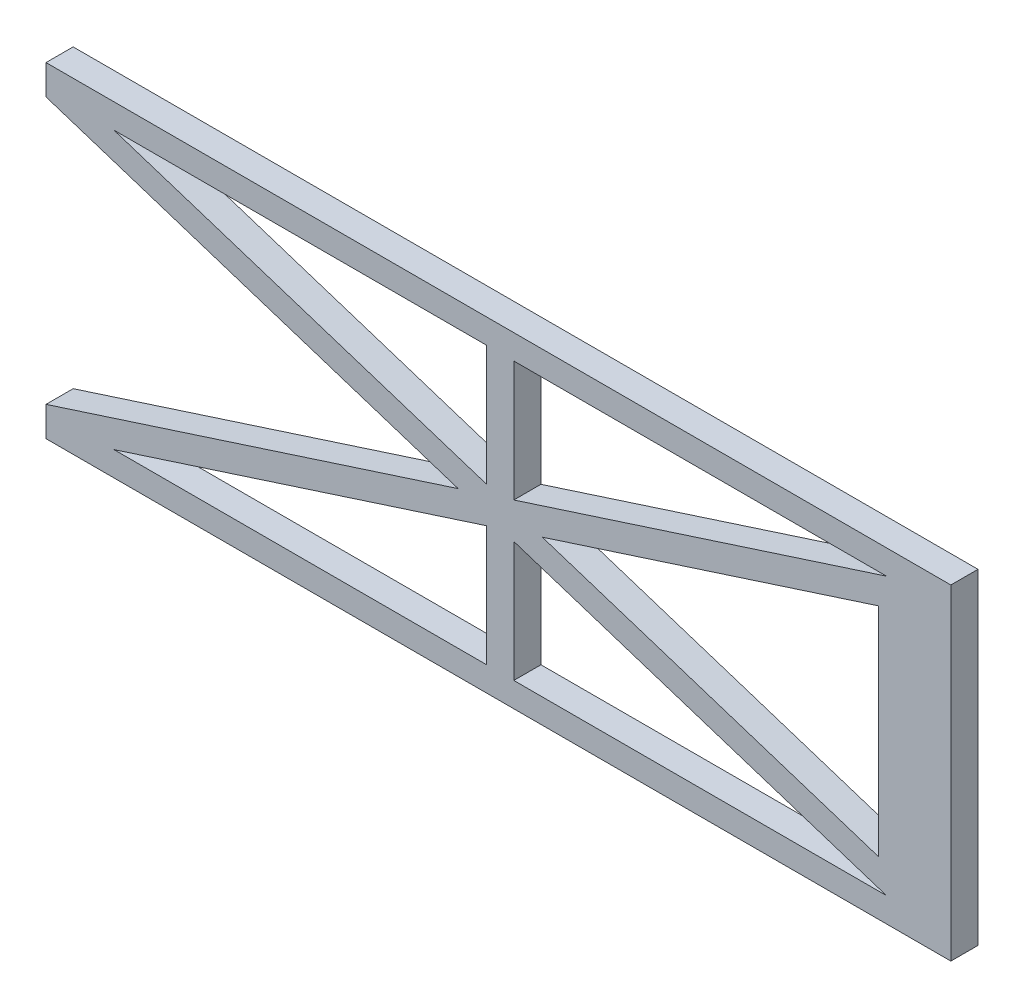
from build123d import *

# Parameters (mm, degrees)
ORIGINAL_TRUSS_PART_DEPTH = 30
SKETCH14_W                = 30
SKETCH14_H                = 30
CENTER_SUPPORT_DEPTH      = 305.758522
RIGHT_SUPPORT_REACH       = 302
SKETCH15_W                = 80
SKETCH15_H                = 30


with BuildPart() as part:
    # Sketch2 → Original Truss Part (new body)
    with BuildSketch(Plane.XY):
        Polygon((0, 0), (-928.915298157, 0), (-928.915298157, 27.120739154), (71.084701843, 27.120739154), (71.084701843, -32.879260846), (-8.915298157, -32.879260846), (-928.915298157, -330), (-928.915298157, -300), align=None)
    original_truss_part = extrude(amount=-ORIGINAL_TRUSS_PART_DEPTH)

    # OG Part Mirror: Original Truss Part across plane
    add(original_truss_part.mirror(Plane.ZX.offset(-152.879260846)))

    # Sketch14 → Center Support (add)
    with BuildSketch(Plane(origin=(0, -305.758521692, 0), x_dir=(1, 0, 0), z_dir=(0, 1, 0))):
        with Locations((-426.927182328, 15)):
            Rectangle(SKETCH14_W, SKETCH14_H)
    extrude(amount=CENTER_SUPPORT_DEPTH)

    # Right Support: up to this plane
    right_support_end = Plane(origin=(-8.915298157, -32.879260846, -30), z_dir=(0.307327428, -0.951603831, 0))
    # Sketch15 → Right Support (add, up to the surface)
    with BuildSketch(Plane(origin=(0, -272.879260846, 0), x_dir=(1, 0, 0), z_dir=(0, 1, 0)), mode=Mode.PRIVATE) as right_support_sk1:
        with Locations((31.084701843, 15)):
            Rectangle(SKETCH15_W, SKETCH15_H)
    right_support_tool1 = split(extrude(right_support_sk1.sketch, amount=RIGHT_SUPPORT_REACH, mode=Mode.PRIVATE), bisect_by=right_support_end, keep=Keep.BOTH, mode=Mode.PRIVATE)
    add(right_support_tool1.solids().sort_by_distance((31.084702, -272.879261, -15))[0])


solid = part.part
